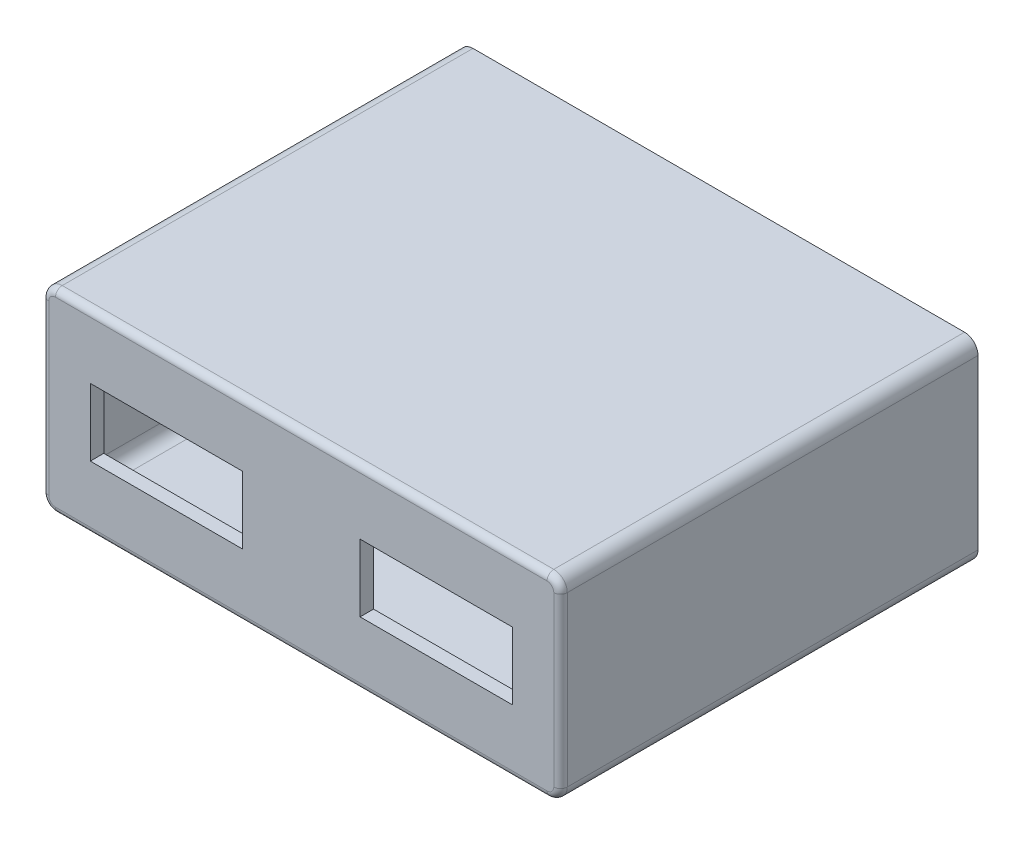
from build123d import *

# Parameters (mm, degrees)
BOSS_EXTRUDE1_DEPTH = 55
BOSS_EXTRUDE2_DEPTH = 2
SKETCH3_W           = 22.6
SKETCH3_H           = 10
CUT_EXTRUDE1_DEPTH  = 12
FILLET1_R           = 1
BOSS_EXTRUDE3_DEPTH = 5


with BuildPart() as part:
    # Sketch1 → Boss-Extrude1 (new body)
    with BuildSketch(Plane.XY):
        with BuildLine():
            Line((36.5, -14.5), (-36.5, -14.5))
            ThreePointArc((-36.5, -14.5), (-37.914213562, -13.914213562), (-38.5, -12.5))
            Line((-38.5, -12.5), (-38.5, 12.5))
            ThreePointArc((-38.5, 12.5), (-37.914213562, 13.914213562), (-36.5, 14.5))
            Line((-36.5, 14.5), (36.5, 14.5))
            ThreePointArc((36.5, 14.5), (37.914213562, 13.914213562), (38.5, 12.5))
            Line((38.5, 12.5), (38.5, -12.5))
            ThreePointArc((38.5, -12.5), (37.914213562, -13.914213562), (36.5, -14.5))
        make_face()
        with BuildLine():
            Line((-34.5, -12.5), (34.5, -12.5))
            ThreePointArc((34.5, -12.5), (35.914213562, -11.914213562), (36.5, -10.5))
            Line((36.5, -10.5), (36.5, 10.5))
            ThreePointArc((36.5, 10.5), (35.914213562, 11.914213562), (34.5, 12.5))
            Line((34.5, 12.5), (-34.5, 12.5))
            ThreePointArc((-34.5, 12.5), (-35.914213562, 11.914213562), (-36.5, 10.5))
            Line((-36.5, 10.5), (-36.5, -10.5))
            ThreePointArc((-36.5, -10.5), (-35.914213562, -11.914213562), (-34.5, -12.5))
        make_face(mode=Mode.SUBTRACT)
    extrude(amount=BOSS_EXTRUDE1_DEPTH)

    # Sketch2 → Boss-Extrude2 (add)
    with BuildSketch(Plane.XY.offset(55)):
        with BuildLine():
            Line((-36.5, -14.5), (36.5, -14.5))
            ThreePointArc((36.5, -14.5), (37.914213562, -13.914213562), (38.5, -12.5))
            Line((38.5, -12.5), (38.5, 12.5))
            ThreePointArc((38.5, 12.5), (37.914213562, 13.914213562), (36.5, 14.5))
            Line((36.5, 14.5), (-36.5, 14.5))
            ThreePointArc((-36.5, 14.5), (-37.914213562, 13.914213562), (-38.5, 12.5))
            Line((-38.5, 12.5), (-38.5, -12.5))
            ThreePointArc((-38.5, -12.5), (-37.914213562, -13.914213562), (-36.5, -14.5))
        make_face()
    extrude(amount=BOSS_EXTRUDE2_DEPTH)

    # Sketch3 → Cut-Extrude1 (cut)
    with BuildSketch(Plane.XY.offset(57)):
        with Locations((-20.033386602, 0)):
            Rectangle(SKETCH3_W, SKETCH3_H)
        with Locations((20.033386602, 0)):
            Rectangle(SKETCH3_W, SKETCH3_H)
    extrude(amount=-CUT_EXTRUDE1_DEPTH, mode=Mode.SUBTRACT)

    # Fillet1
    fillet1_edges = [part.edges().sort_by_distance(p)[0] for p in [
        (-37.914213562, -13.914213562, 57),
        (0, -14.5, 57),
        (37.914213562, -13.914213562, 57),
        (38.5, 0, 57),
        (37.914213562, 13.914213562, 57),
        (0, 14.5, 57),
        (-37.914213562, 13.914213562, 57),
        (-38.5, 0, 57),
    ]]
    fillet(fillet1_edges, radius=FILLET1_R)

    # Sketch4 → Boss-Extrude3 (add)
    with BuildSketch(Plane(origin=(0, 0, 0), x_dir=(-1, 0, 0), z_dir=(0, 0, -1))):
        with BuildLine():
            Line((38.5, -12.5), (38.5, 12.5))
            ThreePointArc((38.5, 12.5), (37.914213562, 13.914213562), (36.5, 14.5))
            Line((36.5, 14.5), (-36.5, 14.5))
            ThreePointArc((-36.5, 14.5), (-37.914213562, 13.914213562), (-38.5, 12.5))
            Line((-38.5, 12.5), (-38.5, -12.5))
            ThreePointArc((-38.5, -12.5), (-37.914213562, -13.914213562), (-36.5, -14.5))
            Line((-36.5, -14.5), (36.5, -14.5))
            ThreePointArc((36.5, -14.5), (37.914213562, -13.914213562), (38.5, -12.5))
        make_face()
        with BuildLine():
            Line((-34.5, -12.5), (34.5, -12.5))
            ThreePointArc((34.5, -12.5), (35.914213562, -11.914213562), (36.5, -10.5))
            Line((36.5, -10.5), (36.5, 10.5))
            ThreePointArc((36.5, 10.5), (35.914213562, 11.914213562), (34.5, 12.5))
            Line((34.5, 12.5), (-34.5, 12.5))
            ThreePointArc((-34.5, 12.5), (-35.914213562, 11.914213562), (-36.5, 10.5))
            Line((-36.5, 10.5), (-36.5, -10.5))
            ThreePointArc((-36.5, -10.5), (-35.914213562, -11.914213562), (-34.5, -12.5))
        make_face(mode=Mode.SUBTRACT)
    extrude(amount=BOSS_EXTRUDE3_DEPTH)


solid = part.part
